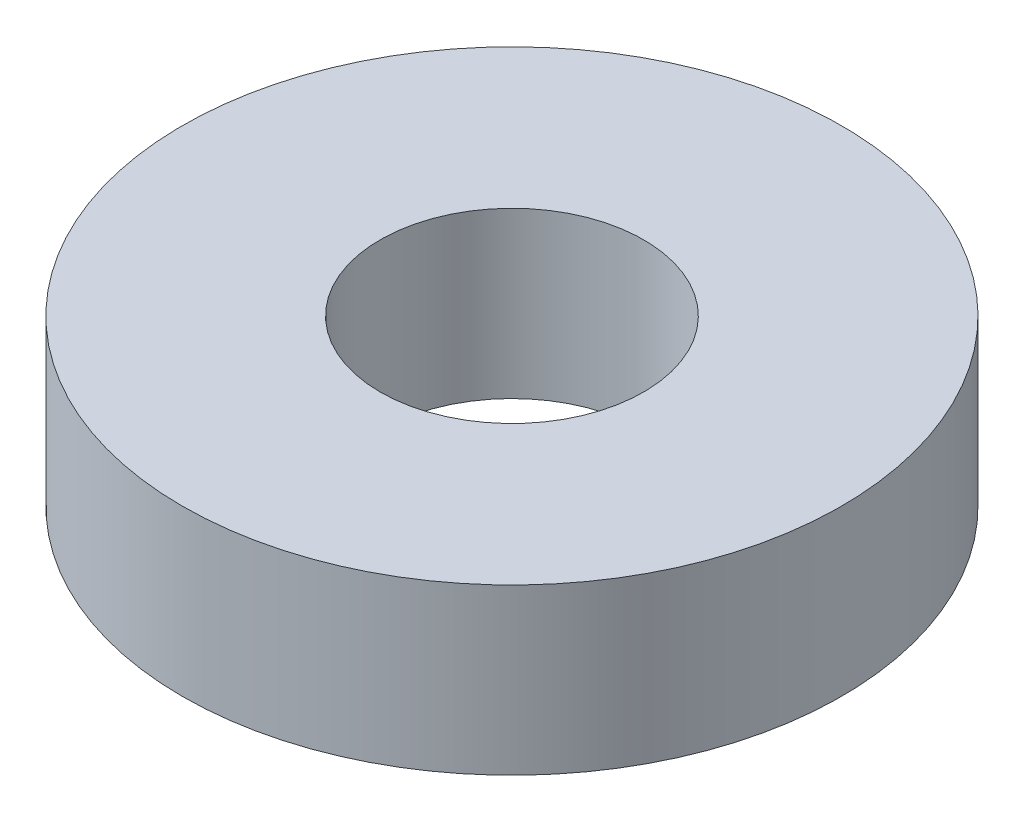
from build123d import *

# Parameters (mm, degrees)
SKETCH1_R           = 10
SKETCH1_R_2         = 4
BOSS_EXTRUDE1_DEPTH = 5


with BuildPart() as part:
    # Sketch1 → Boss-Extrude1 (new body)
    with BuildSketch(Plane(origin=(0, 0, 0), x_dir=(1, 0, 0), z_dir=(0, 1, 0))):
        with Locations(Location((0, 0, 0), (0, 0, 270))):  # turned: the seam where the file's is
            Circle(SKETCH1_R)
        with Locations(Location((0, 0, 0), (0, 0, 270))):  # turned: the seam where the file's is
            Circle(SKETCH1_R_2, mode=Mode.SUBTRACT)
    extrude(amount=BOSS_EXTRUDE1_DEPTH)


solid = part.part
